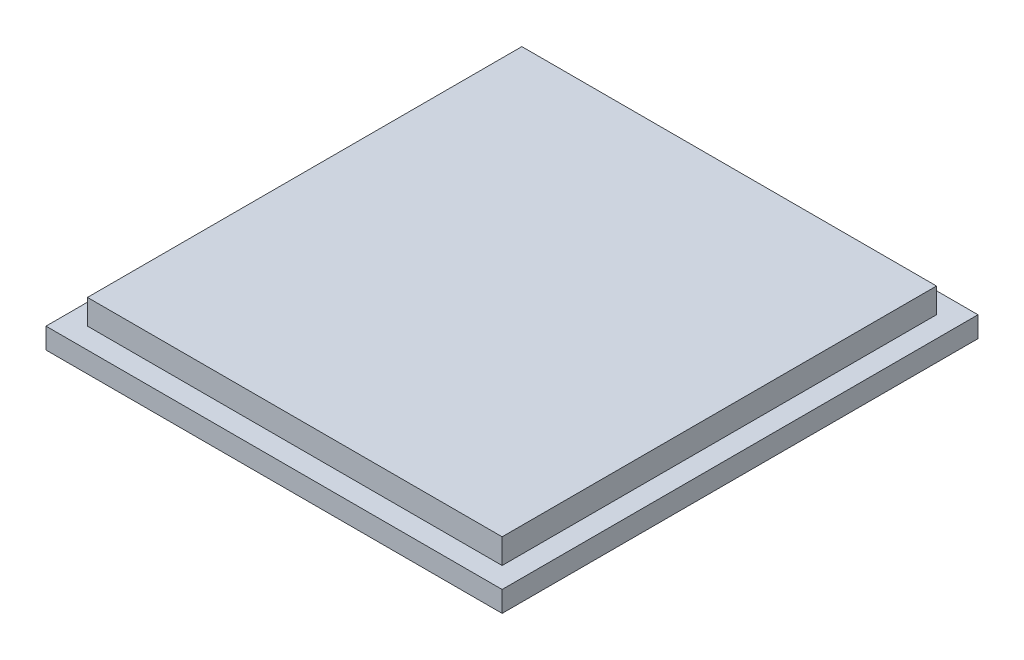
from build123d import *

# Parameters (mm, degrees)
SKETCH1_W           = 69.85
SKETCH1_H           = 72.8726
BOSS_EXTRUDE1_DEPTH = 3.175
SKETCH2_W           = 63.5
SKETCH2_H           = 66.5226
BOSS_EXTRUDE2_DEPTH = 3.81


with BuildPart() as part:
    # Sketch1 → Boss-Extrude1 (new body)
    with BuildSketch(Plane(origin=(0, 0, 0), x_dir=(1, 0, 0), z_dir=(0, 1, 0))):
        Rectangle(SKETCH1_W, SKETCH1_H)
    extrude(amount=BOSS_EXTRUDE1_DEPTH)

    # Sketch2 → Boss-Extrude2 (add)
    with BuildSketch(Plane(origin=(0, 3.175, 0), x_dir=(1, 0, 0), z_dir=(0, 1, 0))):
        Rectangle(SKETCH2_W, SKETCH2_H)
    extrude(amount=BOSS_EXTRUDE2_DEPTH)


solid = part.part
